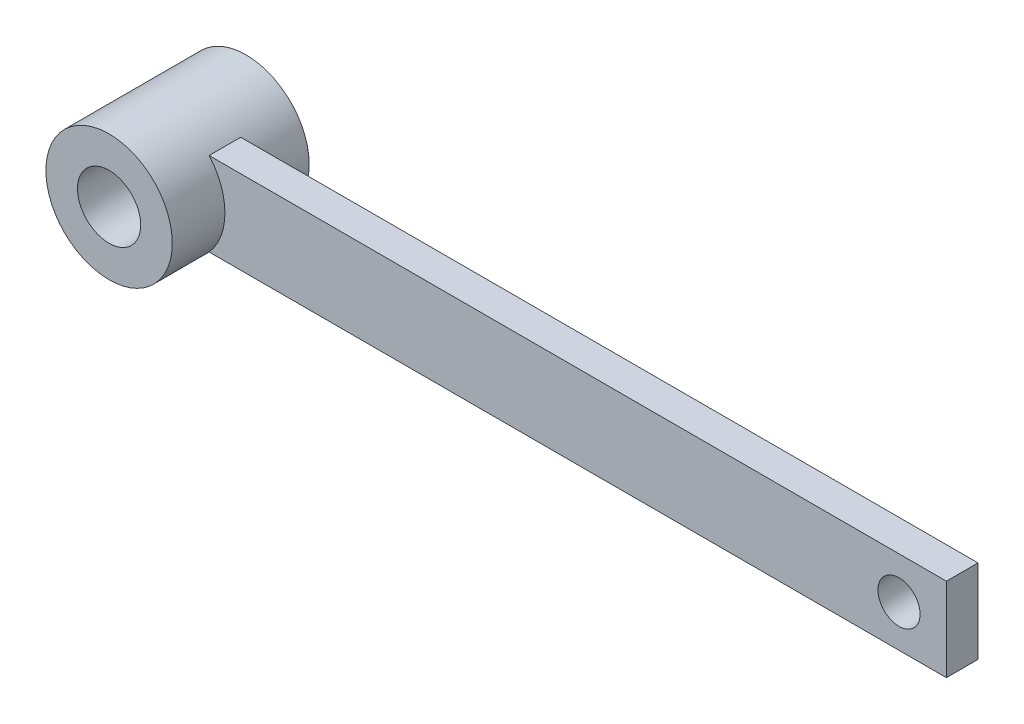
from build123d import *

# Parameters (mm, degrees)
SKETCH1_R                = 6
SKETCH1_R_2              = 3
SKETCH1_W                = 70
SKETCH1_H                = 7.937253934
SKETCH1_R_3              = 2
BOSS_EXTRUDE1_DEPTH      = 3
SKETCH2_R                = 6
SKETCH2_R_2              = 3
BOSS_EXTRUDE2_DEPTH      = 5
BOSS_EXTRUDE2_DEPTH_BACK = 8


with BuildPart() as part:
    # Sketch1 → Boss-Extrude1 (new body)
    with BuildSketch(Plane.XY):
        Circle(SKETCH1_R)
        Circle(SKETCH1_R_2, mode=Mode.SUBTRACT)
        with Locations((39.5, 0)):
            Rectangle(SKETCH1_W, SKETCH1_H)
        with Locations((70, 0)):
            Circle(SKETCH1_R_3, mode=Mode.SUBTRACT)
    extrude(amount=BOSS_EXTRUDE1_DEPTH)

    # Sketch2 → Boss-Extrude2 (add, two sides)
    with BuildSketch(Plane.XY.offset(3)) as boss_extrude2_sk:
        Circle(SKETCH2_R)
        Circle(SKETCH2_R_2, mode=Mode.SUBTRACT)
    extrude(amount=BOSS_EXTRUDE2_DEPTH)
    extrude(boss_extrude2_sk.sketch, amount=-BOSS_EXTRUDE2_DEPTH_BACK)


solid = part.part
